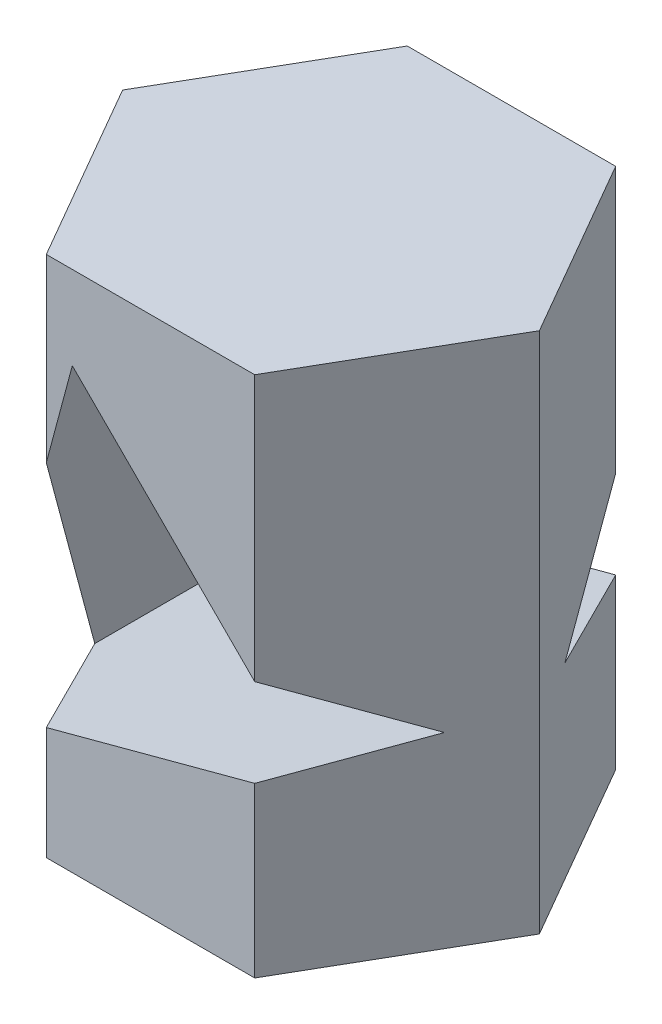
from build123d import *

# Parameters (mm, degrees)
HEXAGONAL_PRISM_DEPTH     = 110
TRIANGULAR_CUT_DEPTH      = 39
TRIANGULAR_CUT_DEPTH_BACK = 39


with BuildPart() as part:
    # Sketch1 → Hexagonal prism (new body)
    with BuildSketch(Plane(origin=(0, 0, 0), x_dir=(1, 0, 0), z_dir=(0, 1, 0))):
        Polygon((43.878620458, 0), (21.939310229, 38), (-21.939310229, 38), (-43.878620458, 0), (-21.939310229, -38), (21.939310229, -38), align=None)
    extrude(amount=HEXAGONAL_PRISM_DEPTH)

    # Sketch2 → Triangular cut (cut, two sides)
    with BuildSketch(Plane.XY) as triangular_cut_sk:
        Polygon((-16.467192076, 92.444436972), (-35.878620458, 20), (36.565816513, 39.411428383), align=None)
    extrude(amount=TRIANGULAR_CUT_DEPTH, mode=Mode.SUBTRACT)
    extrude(triangular_cut_sk.sketch, amount=-TRIANGULAR_CUT_DEPTH_BACK, mode=Mode.SUBTRACT)


solid = part.part
